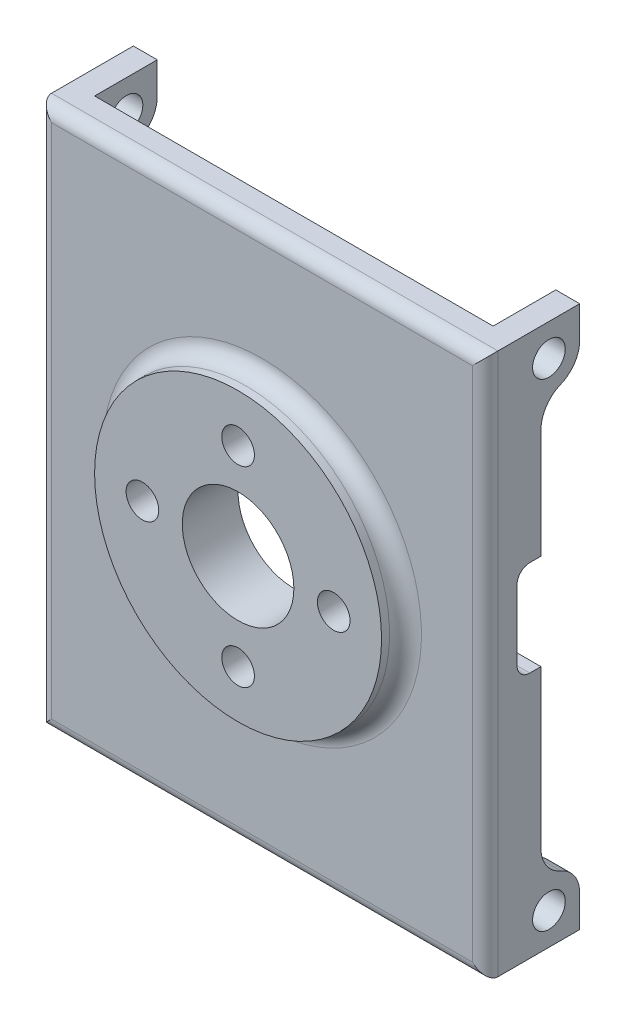
from build123d import *

# Parameters (mm, degrees)
BOSS_EXTRUDE1_DEPTH = 17
SKETCH2_R           = 1.025
CUT_EXTRUDE1_DEPTH  = 50
CUT_EXTRUDE2_DEPTH  = 50
FILLET1_R           = 2
SKETCH8_W           = 1.5
SKETCH8_H           = 6
CUT_EXTRUDE5_DEPTH  = 10
SKETCH9_R           = 9
BOSS_EXTRUDE2_DEPTH = 1.5
SKETCH7_R           = 3.5
SKETCH7_R_2         = 1.025
CUT_EXTRUDE6_DEPTH  = 10
SKETCH10_R          = 2
CUT_EXTRUDE7_DEPTH  = 2
FILLET2_R           = 1
FILLET3_R           = 0.8
FILLET4_R           = 0.8


with BuildPart() as part:
    # Sketch1 → Boss-Extrude1 (new body, symmetric)
    with BuildSketch(Plane(origin=(0, 0, 0), x_dir=(1, 0, 0), z_dir=(0, 1, 0))):
        Polygon((-14, 0), (14, 0), (14, 5.93), (12.5, 5.93), (12.5, 2), (-12.5, 2), (-12.5, 5.93), (-14, 5.93), align=None)
    extrude(amount=BOSS_EXTRUDE1_DEPTH, both=True)

    # Sketch2 → Cut-Extrude1 (cut, symmetric)
    with BuildSketch(Plane(origin=(-12.5, 0, 0), x_dir=(0, 0, -1), z_dir=(1, 0, 0))):
        with Locations((4, 15)):
            Circle(SKETCH2_R)
        with Locations((4, -15)):
            Circle(SKETCH2_R)
    extrude(amount=CUT_EXTRUDE1_DEPTH, both=True, mode=Mode.SUBTRACT)

    # Sketch3 → Cut-Extrude2 (cut, symmetric)
    with BuildSketch(Plane(origin=(14, 0, 0), x_dir=(0, 0, -1), z_dir=(1, 0, 0))):
        with BuildLine():
            Line((3.5, -13.135891634), (3.5, 13.135891634))
            ThreePointArc((3.5, 13.135891634), (5.174712731, 13.468677043), (5.93, 15))
            Line((5.93, 15), (5.93, -15))
            ThreePointArc((5.93, -15), (5.174712731, -13.468677043), (3.5, -13.135891634))
        make_face()
    extrude(amount=CUT_EXTRUDE2_DEPTH, both=True, mode=Mode.SUBTRACT)

    # Fillet1
    fillet1_edges = [part.edges().sort_by_distance(p)[0] for p in [
        (13.25, 13.135891634, -3.5),
        (-13.25, 13.135891634, -3.5),
        (13.25, -13.135891634, -3.5),
        (-13.25, -13.135891634, -3.5),
    ]]
    fillet(fillet1_edges, radius=FILLET1_R)

    # Sketch8 → Cut-Extrude5 (cut)
    with BuildSketch(Plane(origin=(14, 0, 0), x_dir=(0, 0, -1), z_dir=(1, 0, 0))):
        with Locations((2.75, 1.5)):
            Rectangle(SKETCH8_W, SKETCH8_H)
    extrude(amount=-CUT_EXTRUDE5_DEPTH, mode=Mode.SUBTRACT)

    # Sketch9 → Boss-Extrude2 (add)
    with BuildSketch(Plane.XY):
        Circle(SKETCH9_R)
    extrude(amount=BOSS_EXTRUDE2_DEPTH)

    # Sketch7 → Cut-Extrude6 (cut)
    with BuildSketch(Plane.XY.offset(-2)):
        Circle(SKETCH7_R)
        with Locations((0, 6)):
            Circle(SKETCH7_R_2)
        with Locations((0, -6)):
            Circle(SKETCH7_R_2)
        with Locations((6, 0)):
            Circle(SKETCH7_R_2)
        with Locations((-6, 0)):
            Circle(SKETCH7_R_2)
    extrude(amount=CUT_EXTRUDE6_DEPTH, mode=Mode.SUBTRACT)

    # Sketch10 → Cut-Extrude7 (cut)
    with BuildSketch(Plane(origin=(0, 0, -2), x_dir=(-1, 0, 0), z_dir=(0, 0, -1))):
        with Locations((0, 6)):
            Circle(SKETCH10_R)
        with Locations((-6, 0)):
            Circle(SKETCH10_R)
        with Locations((0, -6)):
            Circle(SKETCH10_R)
        with Locations((6, 0)):
            Circle(SKETCH10_R)
    extrude(amount=-CUT_EXTRUDE7_DEPTH, mode=Mode.SUBTRACT)

    # Fillet2
    fillet2_edges = [part.edges().sort_by_distance(p)[0] for p in [
        (-9, 0, 0),
    ]]
    fillet(fillet2_edges, radius=FILLET2_R)

    # Fillet3
    fillet3_edges = [part.edges().sort_by_distance(p)[0] for p in [
        (14, 0, 0),
        (-14, 0, 0),
        (0, 17, 0),
        (0, -17, 0),
    ]]
    fillet(fillet3_edges, radius=FILLET3_R)

    # Fillet4
    fillet4_edges = [part.edges().sort_by_distance(p)[0] for p in [
        (13.25, -1.5, -2),
        (13.25, 4.5, -2),
    ]]
    fillet(fillet4_edges, radius=FILLET4_R)


solid = part.part
